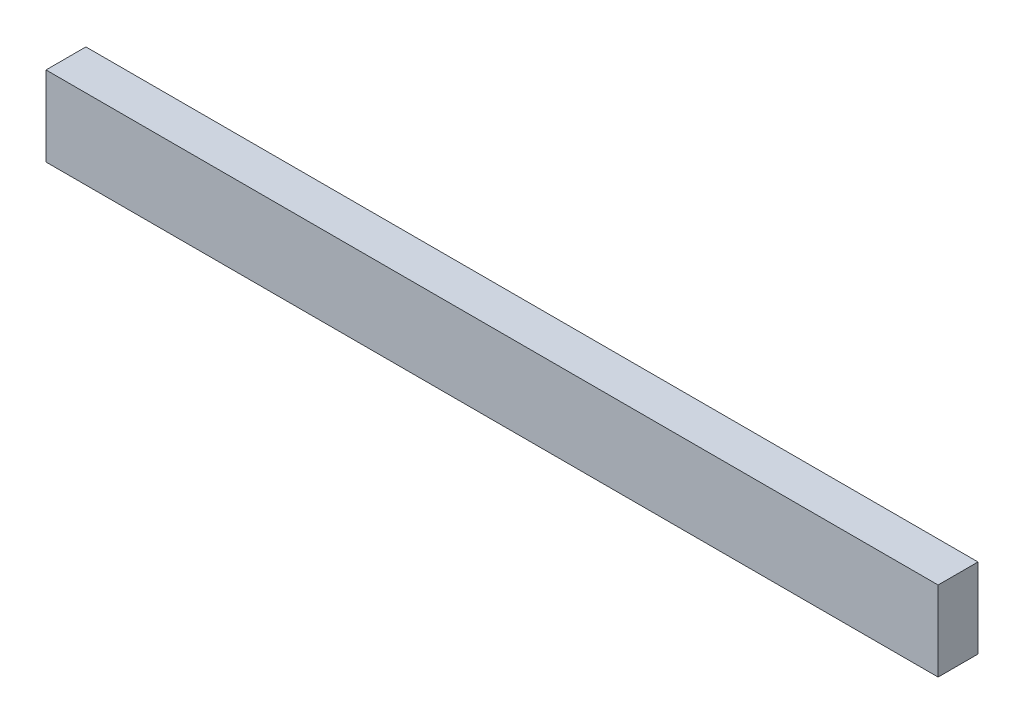
from build123d import *

# Parameters (mm, degrees)
SKETCH1_W           = 25.4
SKETCH1_H           = 50.8
BOSS_EXTRUDE1_DEPTH = 568


with BuildPart() as part:
    # Sketch1 → Boss-Extrude1 (new body)
    with BuildSketch(Plane(origin=(0, 0, 0), x_dir=(0, 0, -1), z_dir=(1, 0, 0))):
        Rectangle(SKETCH1_W, SKETCH1_H)
    extrude(amount=BOSS_EXTRUDE1_DEPTH)


solid = part.part
